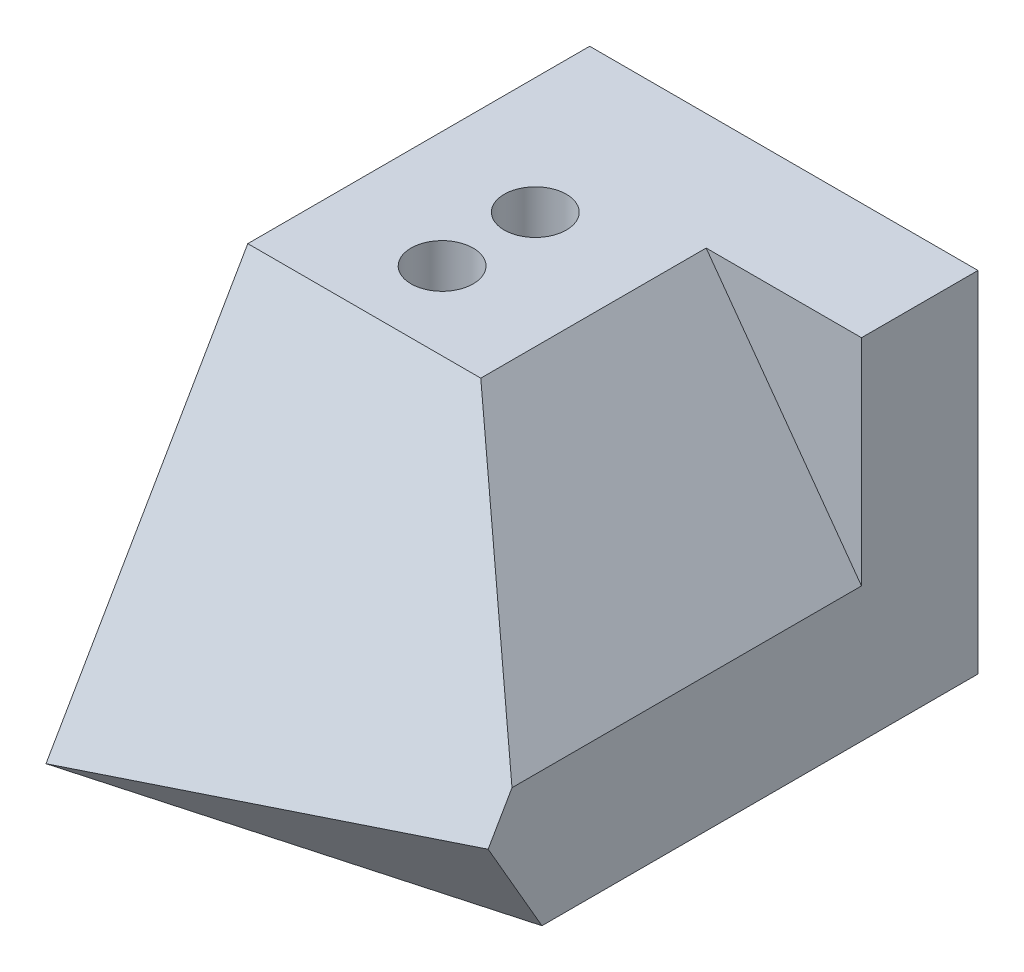
from build123d import *

# Parameters (mm, degrees)
SKETCH1_W           = 50
SKETCH1_H           = 45
BOSS_EXTRUDE1_DEPTH = 35
CUT_EXTRUDE1_DEPTH  = 51
CUT_EXTRUDE2_DEPTH  = 70
SKETCH20_R          = 4
CUT_EXTRUDE5_DEPTH  = 46
CUT_EXTRUDE6_DEPTH  = 56


with BuildPart() as part:
    # Sketch1 → Boss-Extrude1 (new body, symmetric)
    with BuildSketch(Plane.XY):
        with Locations((25, 22.5)):
            Rectangle(SKETCH1_W, SKETCH1_H)
    extrude(amount=BOSS_EXTRUDE1_DEPTH, both=True)

    # Sketch3 → Cut-Extrude1 (cut, through all)
    with BuildSketch(Plane(origin=(0, 0, 0), x_dir=(0, 0, -1), z_dir=(1, 0, 0))):
        Polygon((-35, 45), (-35, 0), (-9.019237886, 45), align=None)
    extrude(amount=CUT_EXTRUDE1_DEPTH, mode=Mode.SUBTRACT)

    # Sketch9 → Cut-Extrude2 (cut, along a direction that is not the sketch's normal)
    with BuildSketch(Plane(origin=(0, 15.155444566, 26.25), x_dir=(1, 0, 0), z_dir=(0, 0.5, 0.866025404))):
        Polygon((50, -17.5), (50, -3.643593539), (0, -17.5), align=None)
    extrude(amount=-CUT_EXTRUDE2_DEPTH, dir=(0, 0.866025404, 0.5), mode=Mode.SUBTRACT)

    # Sketch20 → Cut-Extrude5 (cut, through all)
    with BuildSketch(Plane(origin=(0, 0, 0), x_dir=(1, 0, 0), z_dir=(0, 1, 0))):
        with Locations((15, 13)):
            Circle(SKETCH20_R)
        with Locations((15, 1)):
            Circle(SKETCH20_R)
    extrude(amount=CUT_EXTRUDE5_DEPTH, mode=Mode.SUBTRACT)

    # Sketch23 → Cut-Extrude6 (cut, through all)
    with BuildSketch(Plane.XY.offset(-20)):
        Polygon((50, 45), (30, 45), (50, 17.320508076), align=None)
    extrude(amount=CUT_EXTRUDE6_DEPTH, mode=Mode.SUBTRACT)


solid = part.part
